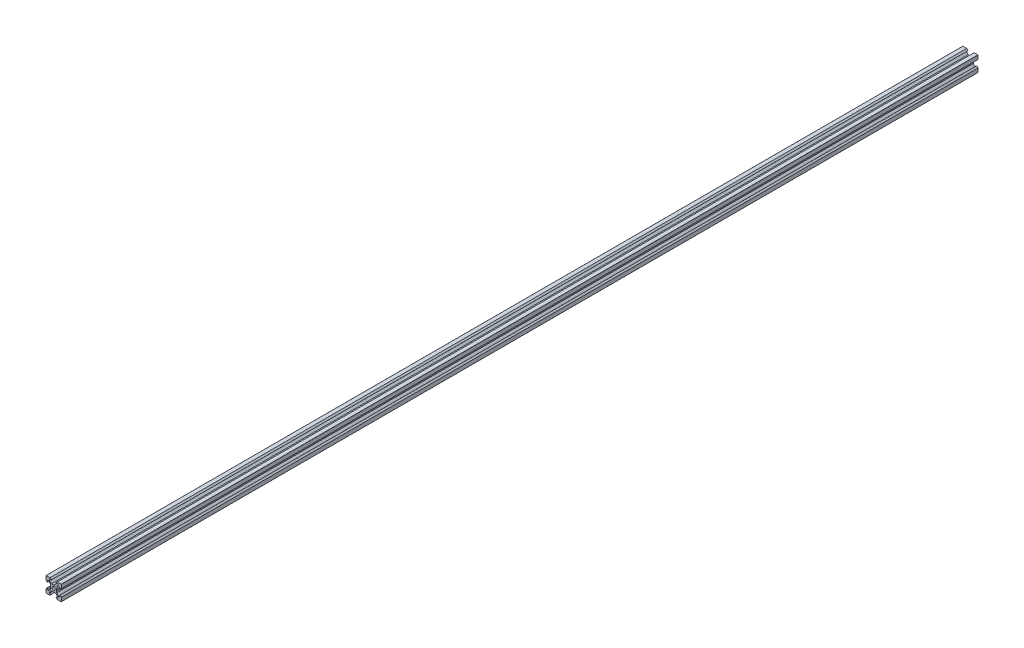
from build123d import *

# Parameters (mm, degrees)
SKETCH1_R           = 2.1
BOSS_EXTRUDE1_DEPTH = 1200


with BuildPart() as part:
    # Sketch1 → Boss-Extrude1 (new body)
    with BuildSketch(Plane.XY):
        with BuildLine():
            Line((-11.623471319, -3.501222945), (-11.623471319, -8.561222945))
            ThreePointArc((-11.623471319, -8.561222945), (-11.582466268, -8.660217894), (-11.483471319, -8.701222945))
            Line((-11.483471319, -8.701222945), (-6.423471319, -8.701222945))
            Line((-6.423471319, -8.701222945), (-4.723471319, -7.001222945))
            Line((-4.723471319, -7.001222945), (-4.723471319, -6.901222945))
            Line((-4.723471319, -6.901222945), (-7.123471319, -6.901222945))
            Line((-7.123471319, -6.901222945), (-7.123471319, -5.261883117))
            Line((-7.123471319, -5.261883117), (-4.462811147, -2.601222945))
            Line((-4.462811147, -2.601222945), (-1.773471319, -2.601222945))
            Line((-1.773471319, -2.601222945), (-1.623471319, -2.451222945))
            Line((-1.623471319, -2.451222945), (-1.473471319, -2.601222945))
            Line((-1.473471319, -2.601222945), (1.215868509, -2.601222945))
            Line((1.215868509, -2.601222945), (3.876528681, -5.261883117))
            Line((3.876528681, -5.261883117), (3.876528681, -6.901222945))
            Line((3.876528681, -6.901222945), (1.476528681, -6.901222945))
            Line((1.476528681, -6.901222945), (1.476528681, -7.001222945))
            Line((1.476528681, -7.001222945), (3.176528681, -8.701222945))
            Line((3.176528681, -8.701222945), (8.236528681, -8.701222945))
            ThreePointArc((8.236528681, -8.701222945), (8.335523631, -8.660217894), (8.376528681, -8.561222945))
            Line((8.376528681, -8.561222945), (8.376528681, -3.501222945))
            Line((8.376528681, -3.501222945), (6.676528681, -1.801222945))
            Line((6.676528681, -1.801222945), (6.576528681, -1.801222945))
            Line((6.576528681, -1.801222945), (6.576528681, -4.201222945))
            Line((6.576528681, -4.201222945), (4.937188853, -4.201222945))
            Line((4.937188853, -4.201222945), (2.276528681, -1.540562773))
            Line((2.276528681, -1.540562773), (2.276528681, 1.148777055))
            Line((2.276528681, 1.148777055), (2.126528681, 1.298777055))
            Line((2.126528681, 1.298777055), (2.276528681, 1.448777055))
            Line((2.276528681, 1.448777055), (2.276528681, 4.138116883))
            Line((2.276528681, 4.138116883), (4.937188853, 6.798777055))
            Line((4.937188853, 6.798777055), (6.576528681, 6.798777055))
            Line((6.576528681, 6.798777055), (6.576528681, 4.398777055))
            Line((6.576528681, 4.398777055), (6.676528681, 4.398777055))
            Line((6.676528681, 4.398777055), (8.376528681, 6.098777055))
            Line((8.376528681, 6.098777055), (8.376528681, 11.158777055))
            ThreePointArc((8.376528681, 11.158777055), (8.335523631, 11.257772004), (8.236528681, 11.298777055))
            Line((8.236528681, 11.298777055), (3.176528681, 11.298777055))
            Line((3.176528681, 11.298777055), (1.476528681, 9.598777055))
            Line((1.476528681, 9.598777055), (1.476528681, 9.498777055))
            Line((1.476528681, 9.498777055), (3.876528681, 9.498777055))
            Line((3.876528681, 9.498777055), (3.876528681, 7.859437227))
            Line((3.876528681, 7.859437227), (1.215868509, 5.198777055))
            Line((1.215868509, 5.198777055), (-1.473471319, 5.198777055))
            Line((-1.473471319, 5.198777055), (-1.623471319, 5.048777055))
            Line((-1.623471319, 5.048777055), (-1.773471319, 5.198777055))
            Line((-1.773471319, 5.198777055), (-4.462811147, 5.198777055))
            Line((-4.462811147, 5.198777055), (-7.123471319, 7.859437227))
            Line((-7.123471319, 7.859437227), (-7.123471319, 9.498777055))
            Line((-7.123471319, 9.498777055), (-4.723471319, 9.498777055))
            Line((-4.723471319, 9.498777055), (-4.723471319, 9.598777055))
            Line((-4.723471319, 9.598777055), (-6.423471319, 11.298777055))
            Line((-6.423471319, 11.298777055), (-11.483471319, 11.298777055))
            ThreePointArc((-11.483471319, 11.298777055), (-11.582466268, 11.257772004), (-11.623471319, 11.158777055))
            Line((-11.623471319, 11.158777055), (-11.623471319, 6.098777055))
            Line((-11.623471319, 6.098777055), (-9.923471319, 4.398777055))
            Line((-9.923471319, 4.398777055), (-9.823471319, 4.398777055))
            Line((-9.823471319, 4.398777055), (-9.823471319, 6.798777055))
            Line((-9.823471319, 6.798777055), (-8.184131491, 6.798777055))
            Line((-8.184131491, 6.798777055), (-5.523471319, 4.138116883))
            Line((-5.523471319, 4.138116883), (-5.523471319, 1.448777055))
            Line((-5.523471319, 1.448777055), (-5.373471319, 1.298777055))
            Line((-5.373471319, 1.298777055), (-5.523471319, 1.148777055))
            Line((-5.523471319, 1.148777055), (-5.523471319, -1.540562773))
            Line((-5.523471319, -1.540562773), (-8.184131491, -4.201222945))
            Line((-8.184131491, -4.201222945), (-9.823471319, -4.201222945))
            Line((-9.823471319, -4.201222945), (-9.823471319, -1.801222945))
            Line((-9.823471319, -1.801222945), (-9.923471319, -1.801222945))
            Line((-9.923471319, -1.801222945), (-11.623471319, -3.501222945))
        make_face()
        with Locations((-1.623471319, 1.298777055)):
            Circle(SKETCH1_R, mode=Mode.SUBTRACT)
    extrude(amount=BOSS_EXTRUDE1_DEPTH)


solid = part.part
